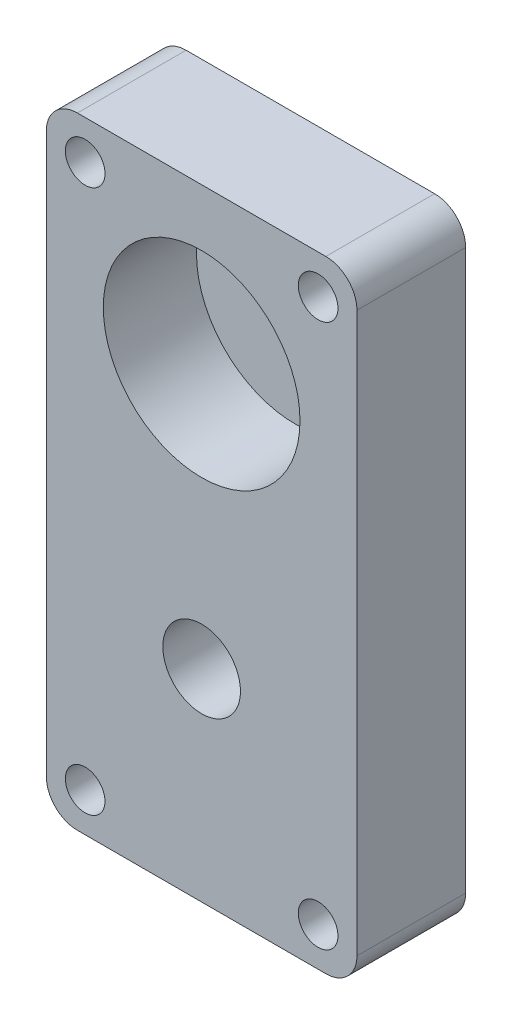
from build123d import *

# Parameters (mm, degrees)
SKETCH1_R           = 12.665
SKETCH1_R_2         = 2.554599
SKETCH1_R_3         = 5
BOSS_EXTRUDE1_DEPTH = 14
FILLET1_R           = 4
SKETCH9_R           = 12.665
BOSS_EXTRUDE2_DEPTH = 2
SKETCH11_R          = 7.5
BOSS_EXTRUDE3_DEPTH = 2


with BuildPart() as part:
    # Sketch1 → Boss-Extrude1 (new body)
    with BuildSketch(Plane.XY):
        Polygon((20, -10), (20, 20), (-20, 20), (-20, -10), (-20, -60), (20, -60), align=None)
        Circle(SKETCH1_R, mode=Mode.SUBTRACT)
        with Locations((-15, 15)):
            Circle(SKETCH1_R_2, mode=Mode.SUBTRACT)
        with Locations((15, 15)):
            Circle(SKETCH1_R_2, mode=Mode.SUBTRACT)
        with Locations((-15, -55)):
            Circle(SKETCH1_R_2, mode=Mode.SUBTRACT)
        with Locations((15, -55)):
            Circle(SKETCH1_R_2, mode=Mode.SUBTRACT)
        with Locations((0, -34)):
            Circle(SKETCH1_R_3, mode=Mode.SUBTRACT)
    extrude(amount=BOSS_EXTRUDE1_DEPTH)

    # Fillet1
    fillet1_edges = [part.edges().sort_by_distance(p)[0] for p in [
        (-20, 20, 7),
        (20, 20, 7),
        (20, -60, 7),
        (-20, -60, 7),
    ]]
    fillet(fillet1_edges, radius=FILLET1_R)

    # Sketch9 → Boss-Extrude2 (add)
    with BuildSketch(Plane(origin=(0, 0, 0), x_dir=(-1, 0, 0), z_dir=(0, 0, -1))):
        Circle(SKETCH9_R)
    extrude(amount=-BOSS_EXTRUDE2_DEPTH)

    # Sketch11 → Boss-Extrude3 (add)
    with BuildSketch(Plane(origin=(0, 0, 0), x_dir=(-1, 0, 0), z_dir=(0, 0, -1))):
        with Locations((0, -34)):
            Circle(SKETCH11_R)
    extrude(amount=-BOSS_EXTRUDE3_DEPTH)


solid = part.part
